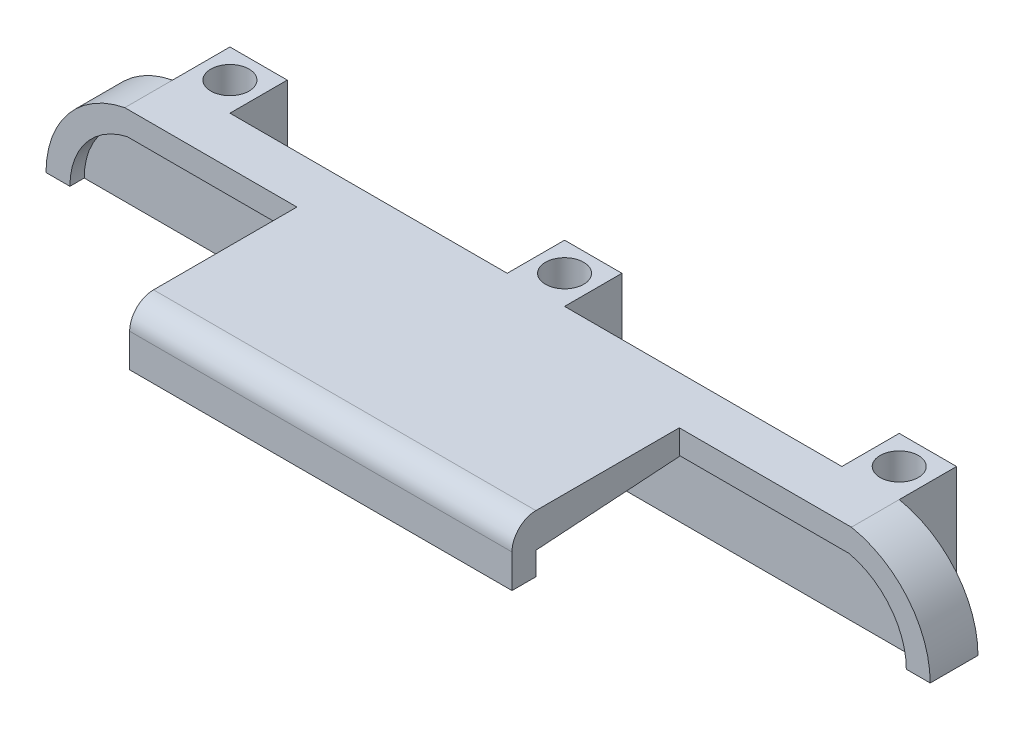
from build123d import *

# Parameters (mm, degrees)
ESTRUSIONE_ESTRUSIONE1_DEPTH  = 10
TAGLIO_ESTRUSIONE1_DEPTH      = 3
SCHIZZO4_W                    = 80
SCHIZZO4_H                    = 5
ESTRUSIONE_ESTRUSIONE2_DEPTH  = 35
ESTRUSIONE_ESTRUSIONE4_DEPTH  = 80
SCHIZZO7_W                    = 80
SCHIZZO7_H                    = 5
ESTRUSIONE_ESTRUSIONE5_DEPTH  = 7
TAGLIO_ESTRUSIONE2_REACH      = 112.369
SCHIZZO8_R                    = 1.5
RACCORDO1_R                   = 5
RACCORDO2_R                   = 5
TAGLIO_ESTRUSIONE3_DEPTH      = 111.368700273
TAGLIO_ESTRUSIONE3_DEPTH_BACK = 10
SCHIZZO11_R                   = 4
TAGLIO_ESTRUSIONE4_DEPTH      = 3
SCHIZZO12_W                   = 12
SCHIZZO12_H                   = 12
ESTRUSIONE_ESTRUSIONE6_DEPTH  = 40
SCHIZZO13_R                   = 1.5
TAGLIO_ESTRUSIONE5_DEPTH      = 111.368700273
SCHIZZO14_R                   = 4
TAGLIO_ESTRUSIONE6_DEPTH      = 10


with BuildPart() as part:
    # Schizzo1 → Estrusione-Estrusione1 (new body)
    with BuildSketch(Plane.XY):
        with BuildLine():
            Line((-76.016095604, 20), (76.016095604, 20))
            ThreePointArc((76.016095604, 20), (92.5, 0), (76.016095604, -20))
            Line((76.016095604, -20), (-76.016095604, -20))
            ThreePointArc((-76.016095604, -20), (-92.5, 0), (-76.016095604, 20))
        make_face()
    extrude(amount=ESTRUSIONE_ESTRUSIONE1_DEPTH)

    # Schizzo3 → Taglio-Estrusione1 (cut)
    with BuildSketch(Plane.XY.offset(10)):
        with BuildLine():
            Line((-75.5, -15), (75.5, -15))
            ThreePointArc((75.5, -15), (87.5, 0), (75.5, 15))
            Line((75.5, 15), (-75.5, 15))
            ThreePointArc((-75.5, 15), (-87.5, 0), (-75.5, -15))
        make_face()
    extrude(amount=-TAGLIO_ESTRUSIONE1_DEPTH, mode=Mode.SUBTRACT)

    # Schizzo4 → Estrusione-Estrusione2 (add)
    with BuildSketch(Plane.XY.offset(10)):
        with Locations((0, -17.5)):
            Rectangle(SCHIZZO4_W, SCHIZZO4_H)
    estrusione_estrusione2 = extrude(amount=ESTRUSIONE_ESTRUSIONE2_DEPTH)

    # Schizzo6 → Estrusione-Estrusione4 (add)
    with BuildSketch(Plane(origin=(40, 0, 0), x_dir=(0, 0, -1), z_dir=(1, 0, 0))):
        Polygon((-40, -15), (-40, -12.81), (-7, -15), align=None)
    estrusione_estrusione4 = extrude(amount=-ESTRUSIONE_ESTRUSIONE4_DEPTH)

    # Schizzo7 → Estrusione-Estrusione5 (add)
    with BuildSketch(Plane(origin=(0, -15, 0), x_dir=(1, 0, 0), z_dir=(0, 1, 0))):
        with Locations((0, -42.5)):
            Rectangle(SCHIZZO7_W, SCHIZZO7_H)
    estrusione_estrusione5 = extrude(amount=ESTRUSIONE_ESTRUSIONE5_DEPTH)

    # Taglio-Estrusione2: up to this plane
    taglio_estrusione2_end = Plane(origin=(-40, -12.81, 40), z_dir=(1.4576135341627736e-15, 0.9978051809344605, -0.0662179801892863))
    # Schizzo8 → Taglio-Estrusione2 (cut, up to the surface)
    with BuildSketch(Plane.XZ.offset(20), mode=Mode.PRIVATE) as taglio_estrusione2_sk1:
        with Locations(Location((-30, 13, 0), (0, 0, 270))):
            Circle(SCHIZZO8_R)
    taglio_estrusione2_tool1 = split(extrude(taglio_estrusione2_sk1.sketch, amount=-TAGLIO_ESTRUSIONE2_REACH, mode=Mode.PRIVATE), bisect_by=taglio_estrusione2_end, keep=Keep.BOTH, mode=Mode.PRIVATE)
    add(taglio_estrusione2_tool1.solids().sort_by_distance((-30, -20, 13))[0], mode=Mode.SUBTRACT)
    # Schizzo8 → Taglio-Estrusione2 (cut, up to the surface)
    with BuildSketch(Plane.XZ.offset(20), mode=Mode.PRIVATE) as taglio_estrusione2_sk2:
        with Locations(Location((-30, 32, 0), (0, 0, 270))):
            Circle(SCHIZZO8_R)
    taglio_estrusione2_tool2 = split(extrude(taglio_estrusione2_sk2.sketch, amount=-TAGLIO_ESTRUSIONE2_REACH, mode=Mode.PRIVATE), bisect_by=taglio_estrusione2_end, keep=Keep.BOTH, mode=Mode.PRIVATE)
    add(taglio_estrusione2_tool2.solids().sort_by_distance((-30, -20, 32))[0], mode=Mode.SUBTRACT)
    # Schizzo8 → Taglio-Estrusione2 (cut, up to the surface)
    with BuildSketch(Plane.XZ.offset(20), mode=Mode.PRIVATE) as taglio_estrusione2_sk3:
        with Locations(Location((30, 13, 0), (0, 0, 270))):
            Circle(SCHIZZO8_R)
    taglio_estrusione2_tool3 = split(extrude(taglio_estrusione2_sk3.sketch, amount=-TAGLIO_ESTRUSIONE2_REACH, mode=Mode.PRIVATE), bisect_by=taglio_estrusione2_end, keep=Keep.BOTH, mode=Mode.PRIVATE)
    add(taglio_estrusione2_tool3.solids().sort_by_distance((30, -20, 13))[0], mode=Mode.SUBTRACT)
    # Schizzo8 → Taglio-Estrusione2 (cut, up to the surface)
    with BuildSketch(Plane.XZ.offset(20), mode=Mode.PRIVATE) as taglio_estrusione2_sk4:
        with Locations(Location((30, 32, 0), (0, 0, 270))):
            Circle(SCHIZZO8_R)
    taglio_estrusione2_tool4 = split(extrude(taglio_estrusione2_sk4.sketch, amount=-TAGLIO_ESTRUSIONE2_REACH, mode=Mode.PRIVATE), bisect_by=taglio_estrusione2_end, keep=Keep.BOTH, mode=Mode.PRIVATE)
    add(taglio_estrusione2_tool4.solids().sort_by_distance((30, -20, 32))[0], mode=Mode.SUBTRACT)

    # Specchia1: Estrusione-Estrusione2, Estrusione-Estrusione4, Estrusione-Estrusione5 across plane
    add(estrusione_estrusione2.mirror(Plane.ZX))
    add(estrusione_estrusione4.mirror(Plane.ZX))
    add(estrusione_estrusione5.mirror(Plane.ZX))

    # Raccordo1
    raccordo1_edges = [part.edges().sort_by_distance(p)[0] for p in [
        (0, -20, 45),
    ]]
    fillet(raccordo1_edges, radius=RACCORDO1_R)

    # Raccordo2
    raccordo2_edges = [part.edges().sort_by_distance(p)[0] for p in [
        (0, 20, 45),
    ]]
    fillet(raccordo2_edges, radius=RACCORDO2_R)

    # Schizzo9 → Taglio-Estrusione3 (cut, two sides)
    with BuildSketch(Plane.XZ.offset(20)) as taglio_estrusione3_sk:
        Polygon((-4, 11), (-4, 3), (4, 3), (4, 11), (10, 11), (10, 31), (-10, 31), (-10, 11), align=None)
    extrude(amount=TAGLIO_ESTRUSIONE3_DEPTH, mode=Mode.SUBTRACT)
    extrude(taglio_estrusione3_sk.sketch, amount=-TAGLIO_ESTRUSIONE3_DEPTH_BACK, mode=Mode.SUBTRACT)

    # Schizzo11 → Taglio-Estrusione4 (cut)
    with BuildSketch(Plane(origin=(0, -15.396736192, 1.021783402), x_dir=(1, 0, 0), z_dir=(1.4576135341627738e-15, 0.9978051809344605, -0.06621798018928632))):
        with Locations(Location((-30, -12.004564445, 0), (0, 0, 270))):
            Circle(SCHIZZO11_R)
        with Locations(Location((-30, -31.046357736, 0), (0, 0, 270))):
            Circle(SCHIZZO11_R)
        with Locations(Location((30, -31.046357736, 0), (0, 0, 270))):
            Circle(SCHIZZO11_R)
        with Locations(Location((30, -12.004564445, 0), (0, 0, 270))):
            Circle(SCHIZZO11_R)
    extrude(amount=-TAGLIO_ESTRUSIONE4_DEPTH, mode=Mode.SUBTRACT)

    # Schizzo12 → Estrusione-Estrusione6 (add)
    with BuildSketch(Plane.XZ.offset(20)):
        with Locations((70.016095604, -6)):
            Rectangle(SCHIZZO12_W, SCHIZZO12_H)
        with Locations((-70.016095604, -6)):
            Rectangle(SCHIZZO12_W, SCHIZZO12_H)
        with Locations((0, -6)):
            Rectangle(SCHIZZO12_W, SCHIZZO12_H)
    extrude(amount=-ESTRUSIONE_ESTRUSIONE6_DEPTH)

    # Schizzo13 → Taglio-Estrusione5 (cut, through all)
    with BuildSketch(Plane.XZ.offset(20)):
        with Locations(Location((-70.016095604, -6, 0), (0, 0, 270))):
            Circle(SCHIZZO13_R)
        with Locations(Location((0, -6, 0), (0, 0, 270))):
            Circle(SCHIZZO13_R)
        with Locations(Location((70.016095604, -6, 0), (0, 0, 270))):
            Circle(SCHIZZO13_R)
    extrude(amount=-TAGLIO_ESTRUSIONE5_DEPTH, mode=Mode.SUBTRACT)

    # Schizzo14 → Taglio-Estrusione6 (cut)
    with BuildSketch(Plane.XZ.offset(20)):
        with Locations(Location((-70.016095604, -6, 0), (0, 0, 270))):
            Circle(SCHIZZO14_R)
        with Locations(Location((0, -6, 0), (0, 0, 270))):
            Circle(SCHIZZO14_R)
        with Locations(Location((70.016095604, -6, 0), (0, 0, 270))):
            Circle(SCHIZZO14_R)
    taglio_estrusione6 = extrude(amount=-TAGLIO_ESTRUSIONE6_DEPTH, mode=Mode.SUBTRACT)

    # Specchia2: Taglio-Estrusione6 across plane
    add(taglio_estrusione6.mirror(Plane.ZX), mode=Mode.SUBTRACT)

    # TaglioSuperficie1
    split(bisect_by=Plane(origin=(0, 0, 0), x_dir=(1, 0, 0), z_dir=(0, 1, 0)), keep=Keep.TOP)


solid = part.part
